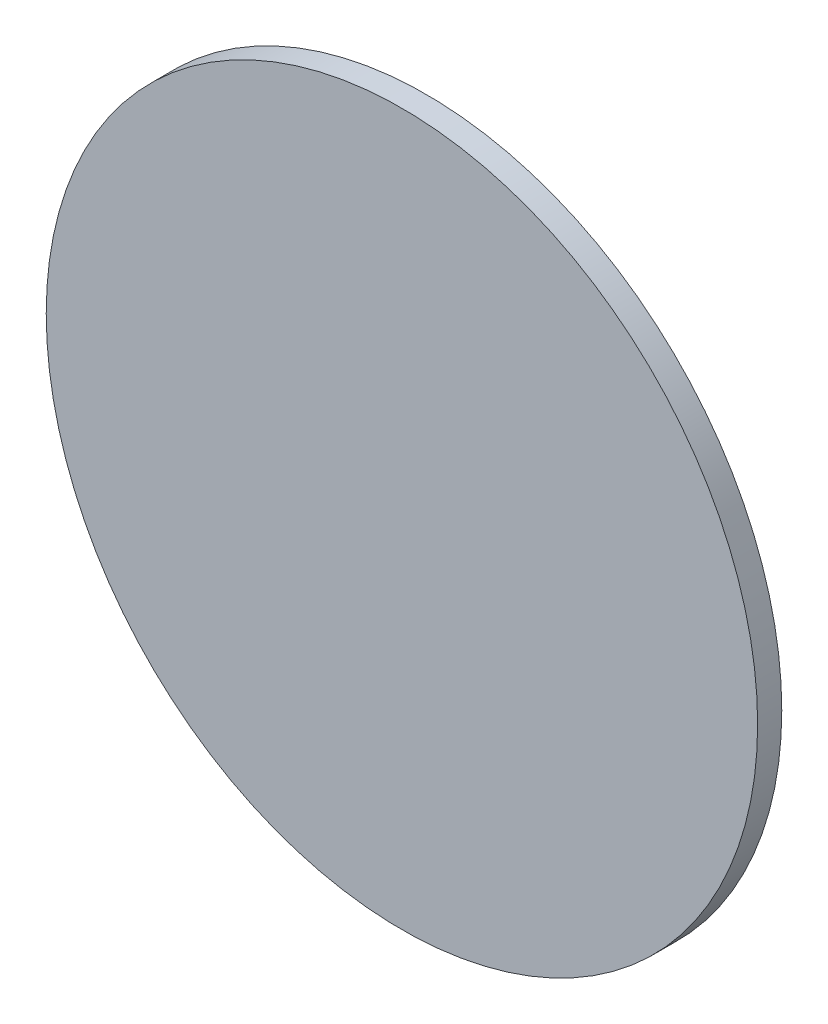
from build123d import *

# Parameters (mm, degrees)
SKETCH1_R           = 147.418002467
BOSS_EXTRUDE1_DEPTH = 10


with BuildPart() as part:
    # Sketch1 → Boss-Extrude1 (new body)
    with BuildSketch(Plane.XY):
        Circle(SKETCH1_R)
    extrude(amount=BOSS_EXTRUDE1_DEPTH)


solid = part.part
